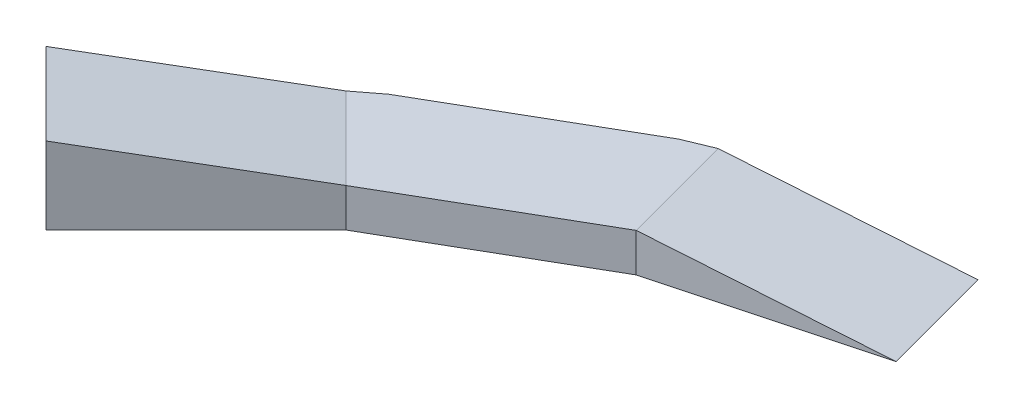
from build123d import *

# Parameters (mm, degrees)
BOSS_EXTRUDE1_DEPTH = 600
CUT_EXTRUDE1_DEPTH  = 600
CUT_EXTRUDE2_DEPTH  = 600
SKETCH26_W          = 1100
SKETCH26_H          = 400
CUT_EXTRUDE3_DEPTH  = 600
SKETCH27_W          = 156.631430664
SKETCH27_H          = 400
CUT_EXTRUDE4_DEPTH  = 600
CUT_EXTRUDE6_DEPTH  = 400
CUT_EXTRUDE7_DEPTH  = 600


with BuildPart() as part:
    # Sketch1 → Boss-Extrude1 (new body)
    with BuildSketch(Plane(origin=(0, 0, 0), x_dir=(1, 0, 0), z_dir=(0, 1, 0))):
        Polygon((0, 0), (-1000, 0), (-2062.518408918, -284.700949613), (-3015.146353081, -834.700949613), (-3792.963812386, -1612.518408918), (-4217.227881098, -1188.254340206), (-3439.410421793, -410.436880901), (-3315.146353081, -315.085707342), (-2362.518408918, 234.914292658), (-2217.809835979, 294.854546161), (-1155.291427062, 579.555495773), (-1000, 600), (0, 600), align=None)
    extrude(amount=-BOSS_EXTRUDE1_DEPTH)

    # Sketch24 → Cut-Extrude1 (cut)
    with BuildSketch(Plane(origin=(0, 0, 0), x_dir=(1, 0, 0), z_dir=(0, 1, 0))):
        Polygon((-1000, 0), (-1155.291427062, 579.555495773), (-1000, 600), (0, 600), (0, 0), align=None)
    extrude(amount=-CUT_EXTRUDE1_DEPTH, mode=Mode.SUBTRACT)

    # Sketch25 → Cut-Extrude2 (cut)
    with BuildSketch(Plane(origin=(-66.987298108, 0, -250), x_dir=(0.96592582628907, 0, -0.2588190451025147), z_dir=(0.25881904510251463, 0, 0.9659258262890699))):
        Polygon((-2065.925826289, -400), (-965.925826289, -600), (-965.925826289, 0), (-2065.925826289, 0), align=None)
    extrude(amount=-CUT_EXTRUDE2_DEPTH, mode=Mode.SUBTRACT)

    # Sketch26 → Cut-Extrude3 (cut)
    with BuildSketch(Plane(origin=(-392.350474806, 0, -679.570956738), x_dir=(0.8660254037844415, 0, -0.4999999999999951), z_dir=(0.49999999999999517, 0, 0.8660254037844416))):
        with Locations((-2478.543812702, -200)):
            Rectangle(SKETCH26_W, SKETCH26_H)
    extrude(amount=-CUT_EXTRUDE3_DEPTH, mode=Mode.SUBTRACT)

    # Sketch27 → Cut-Extrude4 (cut)
    with BuildSketch(Plane(origin=(-429.037555315, 0, -1035.788284809), x_dir=(-0.9238795325112855, 0, 0.38268343236509267), z_dir=(-0.38268343236509267, 0, -0.9238795325112855))):
        with Locations((2014.468880022, -200)):
            Rectangle(SKETCH27_W, SKETCH27_H)
    extrude(amount=-CUT_EXTRUDE4_DEPTH, mode=Mode.SUBTRACT)

    # Sketch30 → Cut-Extrude6 (cut)
    with BuildSketch(Plane(origin=(0, 0, 0), x_dir=(1, 0, 0), z_dir=(0, 1, 0))):
        Polygon((-3439.410421793, -410.436880901), (-3015.146353081, -834.700949613), (-3315.146353081, -315.085707342), align=None)
    extrude(amount=-CUT_EXTRUDE6_DEPTH, mode=Mode.SUBTRACT)

    # Sketch31 → Cut-Extrude7 (cut)
    with BuildSketch(Plane(origin=(-1090.222701734, 0, -1090.222701734), x_dir=(0.7071067811865475, 0, -0.7071067811865477), z_dir=(0.7071067811865477, 0, 0.7071067811865475))):
        Polygon((-2722.253134267, -400), (-3822.253134267, -200), (-3822.253134267, 0), (-2722.253134267, 0), align=None)
    extrude(amount=-CUT_EXTRUDE7_DEPTH, mode=Mode.SUBTRACT)


solid = part.part
